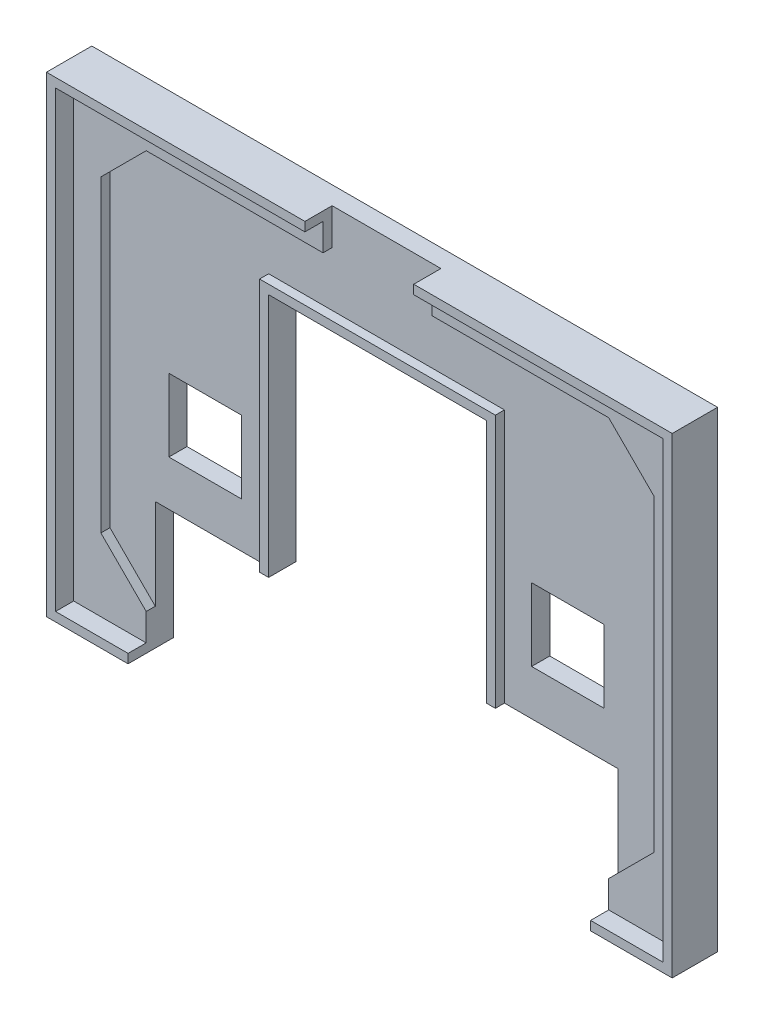
from build123d import *

# Parameters (mm, degrees)
SKICA1_W                    = 67
SKICA1_H                    = 50
P_IDAT_VYSUNUT_M1_DEPTH     = 3
ODEBRAT_VYSUNUT_M1_DEPTH    = 1
SKICA3_W                    = 8
SKICA3_H                    = 8
ODEBRAT_VYSUNUT_M2_DEPTH    = 4
VYSUNOUT_TENKOST_NN_1_DEPTH = 1
VYSUNOUT_TENKOST_NN_2_DEPTH = 5
SKICA6_W                    = 12
SKICA6_H                    = 4
ODEBRAT_VYSUNUT_M3_DEPTH    = 4
SKICA8_W                    = 4.905811643
SKICA8_H                    = 3.97370743
SKICA8_W_2                  = 4.905811642
ODEBRAT_VYSUNUT_M4_DEPTH    = 1
SKICA9_W                    = 2.796312636
SKICA9_H                    = 1.35
P_IDAT_VYSUNUT_M2_DEPTH     = 1
ODEBRAT_VYSUNUT_M5_DEPTH    = 1


with BuildPart() as part:
    # Skica1 → Přidat vysunutím1 (new body)
    with BuildSketch(Plane.XY):
        Rectangle(SKICA1_W, SKICA1_H)
    extrude(amount=P_IDAT_VYSUNUT_M1_DEPTH)

    # Skica2 → Odebrat vysunutím1 (cut)
    with BuildSketch(Plane.XY.offset(3)):
        Polygon((-25.5, -22), (-30.5, -17), (-30.5, 17), (-25.5, 22), (25.5, 22), (30.5, 17), (30.5, -17), (25.5, -22), align=None)
    extrude(amount=-ODEBRAT_VYSUNUT_M1_DEPTH, mode=Mode.SUBTRACT)

    # Skica3 → Odebrat vysunutím2 (cut, through all)
    with BuildSketch(Plane(origin=(0, 0, 0), x_dir=(-1, 0, 0), z_dir=(0, 0, -1))):
        with Locations((20, -3)):
            Rectangle(SKICA3_W, SKICA3_H)
        with Locations((-20, -3)):
            Rectangle(SKICA3_W, SKICA3_H)
        Polygon((25.5, -25), (-25.5, -25), (-25.5, -12), (-12, -12), (-12, 15), (12, 15), (12, -12), (25.5, -12), align=None)
    extrude(amount=-ODEBRAT_VYSUNUT_M2_DEPTH, mode=Mode.SUBTRACT)

    # Skica4 → Vysunout tenkostěnný1 (add)
    with BuildSketch(Plane.XY.offset(2)):
        Polygon((-12, -12), (-12, 15), (12, 15), (12, -12), (13, -12), (13, 16), (-13, 16), (-13, -12), align=None)
    extrude(amount=VYSUNOUT_TENKOST_NN_1_DEPTH)

    # Skica5 → Vysunout tenkostěnný2 (add)
    with BuildSketch(Plane(origin=(0, 0, 0), x_dir=(-1, 0, 0), z_dir=(0, 0, -1))):
        Polygon((-25.5, -25), (-33.5, -25), (-33.5, 25), (33.5, 25), (33.5, -25), (25.5, -25), (25.5, -26), (34.5, -26), (34.5, 26), (-34.5, 26), (-34.5, -26), (-25.5, -26), align=None)
    extrude(amount=-VYSUNOUT_TENKOST_NN_2_DEPTH)

    # Skica6 → Odebrat vysunutím3 (cut, through all)
    with BuildSketch(Plane.XY.offset(2)):
        with Locations((0, 24)):
            Rectangle(SKICA6_W, SKICA6_H)
    extrude(amount=ODEBRAT_VYSUNUT_M3_DEPTH, mode=Mode.SUBTRACT)

    # Skica8 → Odebrat vysunutím4 (cut)
    with BuildSketch(Plane(origin=(0, 0, 0), x_dir=(-1, 0, 0), z_dir=(0, 0, -1))):
        Polygon((-29.360201617, 11.223446344), (-29.360201617, 12.670660778), (-28.060161531, 12.670660778), (-28.060161531, 14.01975898), (-25.06761643, 14.01975898), (-25.06761643, 17.674588653), (-26.463929066, 17.674588653), (-26.463929066, 18.925570622), (-30.65839802, 18.925570622), (-30.65839802, 17.674588653), (-32.05839802, 17.674588653), (-32.05839802, 9.8988772), (-30.68477076, 9.8988772), (-30.68477076, 11.223446344), align=None)
        with Locations((-30.513067353, 22.114348189)):
            Rectangle(SKICA8_W, SKICA8_H)
        Polygon((-21.557554904, 13.547062013), (-23.312585667, 13.547062013), (-23.312585667, 9.373239167), (-21.108219536, 9.373239167), (-21.108219536, 9.8988772), (-20.306572936, 9.8988772), (-20.306572936, 10.925874395), (-21.325302348, 10.925874395), (-21.325302348, 10.184346441), (-22.071409423, 10.184346441), (-22.071409423, 11.947053561), (-21.557554904, 11.947053561), align=None)
        Polygon((-23.312585667, 13.547062013), (-25.06761643, 13.547062013), (-25.06761643, 11.947053561), (-24.553761911, 11.947053561), (-24.553761911, 10.184346441), (-25.299868987, 10.184346441), (-25.299868987, 10.925874395), (-26.318598399, 10.925874395), (-26.318598399, 9.8988772), (-25.516951799, 9.8988772), (-25.516951799, 9.373239167), (-23.312585667, 9.373239167), align=None)
        Polygon((-20.161242268, 18.925570622), (-15.966773314, 18.925570622), (-15.966773314, 17.674588653), (-14.566773314, 17.674588653), (-14.566773314, 9.8988772), (-15.940400574, 9.8988772), (-15.940400574, 11.223446344), (-17.264969718, 11.223446344), (-17.264969718, 12.670660778), (-18.565009803, 12.670660778), (-18.565009803, 14.01975898), (-21.557554904, 14.01975898), (-21.557554904, 17.674588653), (-20.161242268, 17.674588653), align=None)
        with Locations((-16.112103982, 22.114348189)):
            Rectangle(SKICA8_W_2, SKICA8_H)
        with Locations((16.112103982, 22.114348189)):
            Rectangle(SKICA8_W_2, SKICA8_H)
        Polygon((17.264969718, 11.223446344), (17.264969718, 12.670660778), (18.565009803, 12.670660778), (18.565009803, 14.01975898), (21.557554904, 14.01975898), (21.557554904, 17.674588653), (20.161242268, 17.674588653), (20.161242268, 18.925570622), (15.966773314, 18.925570622), (15.966773314, 17.674588653), (14.566773314, 17.674588653), (14.566773314, 9.8988772), (15.940400574, 9.8988772), (15.940400574, 11.223446344), align=None)
        Polygon((26.463929066, 18.925570622), (30.65839802, 18.925570622), (30.65839802, 17.674588653), (32.05839802, 17.674588653), (32.05839802, 9.8988772), (30.68477076, 9.8988772), (30.68477076, 11.223446344), (29.360201617, 11.223446344), (29.360201617, 12.670660778), (28.060161531, 12.670660778), (28.060161531, 14.01975898), (25.06761643, 14.01975898), (25.06761643, 17.674588653), (26.463929066, 17.674588653), align=None)
        with Locations((30.513067353, 22.114348189)):
            Rectangle(SKICA8_W, SKICA8_H)
        Polygon((23.312585667, 13.547062013), (23.312585667, 9.373239167), (25.516951799, 9.373239167), (25.516951799, 9.8988772), (26.318598399, 9.8988772), (26.318598399, 10.925874395), (25.299868987, 10.925874395), (25.299868987, 10.184346441), (24.553761911, 10.184346441), (24.553761911, 11.947053561), (25.06761643, 11.947053561), (25.06761643, 13.547062013), align=None)
        Polygon((21.108219536, 9.8988772), (21.108219536, 9.373239167), (23.312585667, 9.373239167), (23.312585667, 13.547062013), (21.557554904, 13.547062013), (21.557554904, 11.947053561), (22.071409423, 11.947053561), (22.071409423, 10.184346441), (21.325302348, 10.184346441), (21.325302348, 10.925874395), (20.306572936, 10.925874395), (20.306572936, 9.8988772), align=None)
    extrude(amount=-ODEBRAT_VYSUNUT_M4_DEPTH, mode=Mode.SUBTRACT)

    # Skica9 → Přidat vysunutím2 (add)
    with BuildSketch(Plane(origin=(0, 0, 1), x_dir=(-1, 0, 0), z_dir=(0, 0, -1))):
        with Locations((-27.962045299, 14.69475898)):
            Rectangle(SKICA9_W, SKICA9_H)
        with Locations((18.663126036, 14.69475898)):
            Rectangle(SKICA9_W, SKICA9_H)
        with Locations((-18.663126036, 14.69475898)):
            Rectangle(SKICA9_W, SKICA9_H)
        with Locations((27.962045299, 14.69475898)):
            Rectangle(SKICA9_W, SKICA9_H)
    extrude(amount=P_IDAT_VYSUNUT_M2_DEPTH)

    # Skica10 → Odebrat vysunutím5 (cut)
    with BuildSketch(Plane(origin=(0, 0, 0), x_dir=(-1, 0, 0), z_dir=(0, 0, -1))):
        with BuildLine():
            add(Edge.make_bspline(
                [(-10.786907005, 22.633495771), (-10.786266554, 22.662273757), (-10.785065291, 22.716251294), (-10.781015242, 22.792150536), (-10.777826972, 22.858131192), (-10.773419164, 22.914175061), (-10.767018799, 22.960033947), (-10.761783362, 22.995924657), (-10.755050028, 23.021801733), (-10.743304689, 23.046301046), (-10.707137617, 23.064261365), (-10.648706566, 23.075694736), (-10.562846735, 23.084823101), (-10.470072011, 23.088864717), (-10.366127946, 23.092135969), (-10.248626659, 23.092610824), (-10.095176257, 23.09404485), (-9.9057582, 23.095140352), (-9.679976139, 23.096282608), (-9.418230216, 23.097825825), (-9.120116074, 23.097333936), (-8.90951957, 23.097408397), (-8.798027303, 23.097447818)],
                knots=[0, 0, 0, 0, 8.635e-05, 0.000161963, 0.000227997, 0.000284546, 0.000330495, 0.000366956, 0.000393139, 0.00041084, 0.000446424, 0.000506903, 0.000591368, 0.000704219, 0.000785775, 0.000903268, 0.001056724, 0.001246145, 0.001471531, 0.00173408, 0.002031393, 0.00236587, 0.00236587, 0.00236587, 0.00236587], degree=3))
            add(Edge.make_bspline(
                [(-8.798027303, 23.097447818), (-8.721300794, 23.097623006), (-8.572642073, 23.097962435), (-8.356857287, 23.095591203), (-8.155436229, 23.097224082), (-7.968836638, 23.093300977), (-7.796584603, 23.093172861), (-7.638744665, 23.090308063), (-7.494886817, 23.087872512), (-7.365385569, 23.08601749), (-7.250322392, 23.081901362), (-7.149567349, 23.078952324), (-7.063288556, 23.073811114), (-6.991306922, 23.069268529), (-6.933835115, 23.064367368), (-6.890316944, 23.060349086), (-6.861651659, 23.054787307), (-6.83989128, 23.047755157), (-6.827627065, 23.028047679), (-6.816100638, 23.001964189), (-6.805409555, 22.966852234), (-6.797149634, 22.922717171), (-6.791991561, 22.86933108), (-6.786774702, 22.807019906), (-6.784944001, 22.73580466), (-6.784309323, 22.685444484), (-6.783971908, 22.658671464)],
                knots=[0, 0, 0, 0, 0.000230178, 0.000445973, 0.000647378, 0.000834413, 0.001005852, 0.001164117, 0.001307998, 0.001437495, 0.00155264, 0.001653407, 0.001739857, 0.001811947, 0.001869691, 0.001913115, 0.001942505, 0.00195809, 0.001979435, 0.002008406, 0.002044808, 0.002088775, 0.002143055, 0.002205579, 0.002276351, 0.002356683, 0.002356683, 0.002356683, 0.002356683], degree=3))
            Line((-6.783971908, 22.658671464), (-6.783971908, 22.31100714))
            Line((-6.783971908, 22.31100714), (-6.519027716, 22.31100714))
            Line((-6.519027716, 22.31100714), (-6.402739994, 22.31100714))
            add(Edge.make_bspline(
                [(-6.402739994, 22.31100714), (-6.376684614, 22.310020117), (-6.328998931, 22.308213701), (-6.264901459, 22.291852058), (-6.217525297, 22.260107453), (-6.192127032, 22.222101776), (-6.182431537, 22.182930855), (-6.173354125, 22.14317585), (-6.168504966, 22.092069951), (-6.163927997, 22.030508761), (-6.158409105, 21.958626782), (-6.157195089, 21.875419522), (-6.153807933, 21.781540283), (-6.154314269, 21.715186475), (-6.154579597, 21.680415986)],
                knots=[0, 0, 0, 0, 7.8155e-05, 0.000143037, 0.000195581, 0.000245789, 0.00027576, 0.000316203, 0.0003681, 0.000429429, 0.000501519, 0.000584274, 0.000679013, 0.000783312, 0.000783312, 0.000783312, 0.000783312], degree=3))
            Line((-6.154579597, 21.680415986), (-6.154579597, 21.383103047))
            add(Edge.make_bspline(
                [(-6.154579597, 21.383103047), (-6.155058222, 21.319965229), (-6.155957917, 21.20128179), (-6.15604519, 21.034613396), (-6.160588411, 20.891170494), (-6.16316869, 20.77084373), (-6.168956341, 20.673599539), (-6.176496263, 20.599440439), (-6.182124106, 20.547278766), (-6.191852254, 20.521857931), (-6.195340242, 20.512743394)],
                knots=[0, 0, 0, 0, 0.000189421, 0.000356064, 0.00049997, 0.000619909, 0.0007172, 0.000791875, 0.000844104, 0.000873298, 0.000873298, 0.000873298, 0.000873298], degree=3))
            add(Edge.make_bspline(
                [(-6.195340242, 20.512743394), (-6.2069217, 20.503571286), (-6.23601227, 20.480532576), (-6.304213399, 20.465201193), (-6.397481857, 20.455352631), (-6.469777853, 20.454488484), (-6.510635819, 20.454000112)],
                knots=[0, 0, 0, 0, 4.3901e-05, 0.000110272, 0.000204402, 0.000326737, 0.000326737, 0.000326737, 0.000326737], degree=3))
            Line((-6.510635819, 20.454000112), (-6.783971908, 20.454000112))
            Line((-6.783971908, 20.454000112), (-6.783971908, 20.114727685))
            add(Edge.make_bspline(
                [(-6.783971908, 20.114727685), (-6.784257461, 20.087151703), (-6.784791433, 20.035585806), (-6.787247214, 19.962446481), (-6.790601158, 19.898859863), (-6.795259872, 19.844042527), (-6.801314369, 19.798862688), (-6.812252733, 19.763267815), (-6.819896912, 19.735808941), (-6.835244345, 19.711605643), (-6.876691653, 19.701097412), (-6.942376853, 19.693837875), (-7.045320495, 19.683430325), (-7.183501547, 19.678040096), (-7.357772143, 19.669771831), (-7.568410481, 19.666411346), (-7.814552884, 19.660581657), (-7.990802718, 19.659659109), (-8.084716017, 19.659167537)],
                knots=[0, 0, 0, 0, 8.2729e-05, 0.000154699, 0.000219537, 0.000273697, 0.000319818, 0.000355883, 0.000385076, 0.000405702, 0.000437982, 0.000505799, 0.000608151, 0.000746205, 0.000921384, 0.001131236, 0.001378244, 0.001659982, 0.001659982, 0.001659982, 0.001659982], degree=3))
            Line((-8.084716017, 19.659167537), (-9.302739994, 19.650775639))
            Line((-9.302739994, 19.650775639), (-9.302739994, 18.53225559))
            add(Edge.make_bspline(
                [(-9.302739994, 18.53225559), (-9.303427373, 18.444740909), (-9.304717434, 18.280494864), (-9.308175997, 18.050683803), (-9.312999066, 17.853735098), (-9.318237049, 17.689655129), (-9.326409208, 17.559522224), (-9.330997438, 17.460560055), (-9.342150664, 17.398393473), (-9.347620268, 17.354831871), (-9.377806854, 17.337867599), (-9.417057985, 17.327941067), (-9.47601302, 17.318790607), (-9.553104164, 17.310618034), (-9.649972093, 17.30531378), (-9.765441105, 17.30023359), (-9.900559718, 17.298409424), (-9.996870749, 17.297783067), (-10.048420027, 17.297447818)],
                knots=[0, 0, 0, 0, 0.000262557, 0.000492763, 0.000689432, 0.000853783, 0.000984654, 0.001082027, 0.001147471, 0.001180083, 0.00120336, 0.001244698, 0.001303037, 0.001381412, 0.001477506, 0.001593893, 0.001728185, 0.00188284, 0.00188284, 0.00188284, 0.00188284], degree=3))
            add(Edge.make_bspline(
                [(-10.048420027, 17.297447818), (-10.08598352, 17.297487035), (-10.156714777, 17.29756088), (-10.257023598, 17.297074039), (-10.345334758, 17.298616002), (-10.422458822, 17.299772489), (-10.487603133, 17.300839712), (-10.541135832, 17.3022989), (-10.582764272, 17.302779621), (-10.62115527, 17.306139392), (-10.658083057, 17.310210987), (-10.694479459, 17.321147791), (-10.723630137, 17.335083955), (-10.744318498, 17.351504239), (-10.755127017, 17.372986414), (-10.761749218, 17.39901863), (-10.767032188, 17.434843116), (-10.773413821, 17.480727406), (-10.777830936, 17.53676205), (-10.781004014, 17.602746098), (-10.785114305, 17.678643064), (-10.786482752, 17.750209882), (-10.788581336, 17.818135039), (-10.787682518, 17.8836888), (-10.789501758, 17.962403189), (-10.790910773, 18.054711825), (-10.790021921, 18.160219317), (-10.792217834, 18.279295156), (-10.791628255, 18.411572608), (-10.791365117, 18.557433989), (-10.793342184, 18.716074949), (-10.792857994, 18.88831204), (-10.79253785, 19.073735053), (-10.794561554, 19.272738054), (-10.793964515, 19.484936166), (-10.79414007, 19.710717645), (-10.794087699, 19.949687067), (-10.794106392, 20.197447818), (-10.794087699, 20.445208568), (-10.79414007, 20.68417799), (-10.793964515, 20.90995947), (-10.794561554, 21.122157582), (-10.792537849, 21.321160583), (-10.792857995, 21.506583596), (-10.793342181, 21.678820687), (-10.791365127, 21.837461647), (-10.791628222, 21.983323027), (-10.792217943, 22.115600482), (-10.790021577, 22.234676311), (-10.790911842, 22.340183833), (-10.789498512, 22.432492377), (-10.787691993, 22.511207038), (-10.788555095, 22.576760038), (-10.787417731, 22.615913959), (-10.786907005, 22.633495771)],
                knots=[0, 0, 0, 0, 0.000112691, 0.000212195, 0.000300918, 0.000377653, 0.0004436, 0.000496363, 0.000538339, 0.000568406, 0.000611979, 0.000649528, 0.000681696, 0.000708876, 0.000726576, 0.000752759, 0.000789221, 0.000835169, 0.000891719, 0.000957753, 0.001033366, 0.001119716, 0.001172478, 0.001237216, 0.001316349, 0.001408667, 0.001514165, 0.001632857, 0.001765928, 0.001910988, 0.002070439, 0.002241873, 0.002427694, 0.002626705, 0.002838901, 0.003064283, 0.003304051, 0.003555808, 0.003807565, 0.004047334, 0.004272716, 0.004484911, 0.004683923, 0.004869743, 0.005041178, 0.005200628, 0.005345688, 0.00547876, 0.005597451, 0.005702949, 0.005795268, 0.005874401, 0.005939138, 0.005991901, 0.005991901, 0.005991901, 0.005991901], degree=3))
        make_face()
        with BuildLine():
            add(Edge.make_bspline(
                [(-7.645939663, 20.744119996), (-7.645939663, 20.745718453), (-7.645939663, 20.752511894), (-7.645939663, 20.767297618), (-7.645939663, 20.79247331), (-7.645939663, 20.827239743), (-7.645939663, 20.872396144), (-7.645939663, 20.927143284), (-7.645939663, 20.991880779), (-7.645939663, 21.066608628), (-7.645939663, 21.151326831), (-7.645939663, 21.246035388), (-7.645939663, 21.3507343), (-7.645939663, 21.465423565), (-7.645939663, 21.590103185), (-7.645939663, 21.724773159), (-7.645939663, 21.869433487), (-7.645939663, 21.969337028), (-7.645939663, 22.020887256)],
                knots=[0, 0, 0, 0, 4.795e-06, 2.038e-05, 4.4357e-05, 8.0322e-05, 0.00012468, 0.000179826, 0.000244564, 0.000318892, 0.00040401, 0.000498718, 0.000603018, 0.000718107, 0.000842786, 0.000977057, 0.001122117, 0.001276767, 0.001276767, 0.001276767, 0.001276767], degree=3))
            Line((-7.645939663, 22.020887256), (-8.465947931, 22.029279153))
            add(Edge.make_bspline(
                [(-8.465947931, 22.029279153), (-8.467946002, 22.029279153), (-8.475538671, 22.029279153), (-8.49272208, 22.029279153), (-8.521094686, 22.029279153), (-8.561056102, 22.029279153), (-8.612206716, 22.029279153), (-8.67494614, 22.029279153), (-8.74887476, 22.029279153), (-8.802023444, 22.029279153), (-8.83039605, 22.029279153)],
                knots=[0, 0, 0, 0, 5.994e-06, 2.2778e-05, 5.155e-05, 9.1112e-05, 0.000142662, 0.000205002, 0.00027933, 0.000364448, 0.000364448, 0.000364448, 0.000364448], degree=3))
            add(Edge.make_bspline(
                [(-8.83039605, 22.029279153), (-8.866766038, 22.029547199), (-8.934720089, 22.030048018), (-9.029389514, 22.026832372), (-9.109805544, 22.025100351), (-9.175619666, 22.021369249), (-9.228072176, 22.017516708), (-9.264761269, 22.010439712), (-9.291084514, 22.007662706), (-9.299711199, 21.998817189), (-9.302739994, 21.995711563)],
                knots=[0, 0, 0, 0, 0.000109095, 0.000203834, 0.000284192, 0.000350226, 0.000401999, 0.000440827, 0.000464381, 0.000477125, 0.000477125, 0.000477125, 0.000477125], degree=3))
            add(Edge.make_bspline(
                [(-9.302739994, 21.995711563), (-9.302739994, 21.991715421), (-9.302739994, 21.975331241), (-9.302739994, 21.95894706), (-9.302739994, 21.946559021)],
                knots=[0, 0, 0, 0, 1.1988e-05, 4.9153e-05, 4.9153e-05, 4.9153e-05, 4.9153e-05], degree=3))
            add(Edge.make_bspline(
                [(-9.302739994, 21.946559021), (-9.302991214, 21.926972671), (-9.30356061, 21.882579764), (-9.308191959, 21.810731561), (-9.310084785, 21.73077668), (-9.310782893, 21.675620825), (-9.311131891, 21.648047239)],
                knots=[0, 0, 0, 0, 5.8756e-05, 0.000133171, 0.000215926, 0.000298654, 0.000298654, 0.000298654, 0.000298654], degree=3))
            add(Edge.make_bspline(
                [(-9.311131891, 21.648047239), (-9.310740066, 21.629265338), (-9.309756232, 21.582105947), (-9.307915382, 21.505358536), (-9.303601104, 21.4246963), (-9.303001007, 21.3723176), (-9.302739994, 21.349535457)],
                knots=[0, 0, 0, 0, 5.6358e-05, 0.00014151, 0.000230297, 0.000298642, 0.000298642, 0.000298642, 0.000298642], degree=3))
            Line((-9.302739994, 21.349535457), (-9.302739994, 20.744119996))
            Line((-9.302739994, 20.744119996), (-7.645939663, 20.744119996))
        make_face(mode=Mode.SUBTRACT)
        with BuildLine():
            add(Edge.make_bspline(
                [(-4.717167443, 22.658671464), (-4.716827908, 22.685443889), (-4.716189241, 22.735802946), (-4.714384721, 22.807025537), (-4.709085605, 22.869313634), (-4.704173112, 22.922768623), (-4.695247109, 22.9666005), (-4.686502275, 23.002139329), (-4.674672244, 23.02808247), (-4.662621781, 23.047310204), (-4.642783018, 23.054705887), (-4.617606748, 23.060294909), (-4.580114603, 23.064362722), (-4.53140626, 23.069188024), (-4.470630541, 23.073878804), (-4.398331738, 23.078893445), (-4.313957265, 23.081915812), (-4.218078825, 23.086012518), (-4.110152103, 23.087874222), (-3.990271554, 23.090306706), (-3.858408249, 23.093183948), (-3.714924401, 23.093281483), (-3.559499168, 23.097236645), (-3.392441604, 23.095568452), (-3.21342277, 23.098038679), (-3.026799523, 23.097142799), (-2.840176275, 23.098038678), (-2.661157441, 23.095568457), (-2.494099878, 23.097236631), (-2.338674641, 23.09328153), (-2.195190806, 23.093183792), (-2.063327459, 23.090307214), (-1.943447046, 23.087872584), (-1.835519889, 23.08601772), (-1.739642811, 23.081899607), (-1.655662706, 23.078956968), (-1.58337568, 23.073765469), (-1.522591139, 23.069224246), (-1.473866892, 23.064482268), (-1.436811033, 23.060181017), (-1.412011102, 23.054710186), (-1.3921843, 23.047306799), (-1.380070442, 23.028099178), (-1.368566619, 23.001944348), (-1.357866994, 22.966859353), (-1.349610147, 22.922714586), (-1.344450977, 22.869331957), (-1.339234486, 22.807019623), (-1.337403668, 22.735804746), (-1.336769007, 22.685444514), (-1.336431602, 22.658671464)],
                knots=[0, 0, 0, 0, 8.0331e-05, 0.000151104, 0.000213628, 0.000267908, 0.000311874, 0.000347939, 0.000376911, 0.000398255, 0.000412741, 0.000438621, 0.000476093, 0.000525479, 0.000585612, 0.000658899, 0.000742895, 0.00083887, 0.000946792, 0.0010667, 0.001198595, 0.001342461, 0.00149713, 0.001664968, 0.0018436, 0.002034216, 0.002224831, 0.002403463, 0.002571301, 0.00272597, 0.002869836, 0.003001731, 0.003121639, 0.003229562, 0.003325536, 0.003409532, 0.003481623, 0.003542951, 0.003592337, 0.003628621, 0.0036545, 0.003668986, 0.003690331, 0.003719302, 0.003755704, 0.003799671, 0.003853951, 0.003916475, 0.003987247, 0.004067578, 0.004067578, 0.004067578, 0.004067578], degree=3))
            Line((-1.336431602, 22.658671464), (-1.336431602, 22.31100714))
            Line((-1.336431602, 22.31100714), (-1.07148741, 22.31100714))
            add(Edge.make_bspline(
                [(-1.07148741, 22.31100714), (-1.032588592, 22.310863789), (-0.962909488, 22.310607005), (-0.871901657, 22.296740203), (-0.801121071, 22.280595688), (-0.769650093, 22.254872312), (-0.756191833, 22.24387196)],
                knots=[0, 0, 0, 0, 0.000116343, 0.000208405, 0.000277419, 0.000328983, 0.000328983, 0.000328983, 0.000328983], degree=3))
            add(Edge.make_bspline(
                [(-0.756191833, 22.24387196), (-0.75094349, 22.231614308), (-0.736091374, 22.196926772), (-0.728354317, 22.123214277), (-0.719923924, 22.017149601), (-0.716158454, 21.919401896), (-0.714167555, 21.838667832), (-0.712580792, 21.782325483), (-0.713448724, 21.71477648), (-0.711662665, 21.635661342), (-0.71022035, 21.544951837), (-0.711146892, 21.443040279), (-0.708821073, 21.329959703), (-0.709988439, 21.20527041), (-0.707731247, 21.069010357), (-0.708300383, 20.9211487), (-0.708596949, 20.762100009), (-0.706577682, 20.591470404), (-0.707174671, 20.409642467), (-0.70699945, 20.216229821), (-0.707051618, 20.011627193), (-0.707032993, 19.799432109), (-0.707051525, 19.587237024), (-0.706999795, 19.382634398), (-0.707173129, 19.189621356), (-0.706583773, 19.00779347), (-0.708591049, 18.837563397), (-0.708300025, 18.678514744), (-0.707731508, 18.531052707), (-0.709986574, 18.394792633), (-0.708823632, 18.269703805), (-0.711148082, 18.156223523), (-0.710213558, 18.054311906), (-0.711688671, 17.96360267), (-0.713445252, 17.884487779), (-0.712580822, 17.816537189), (-0.714172494, 17.760200845), (-0.716129588, 17.67943773), (-0.720247599, 17.582399287), (-0.727502752, 17.47577936), (-0.73801173, 17.403986574), (-0.751732717, 17.356762453), (-0.778459518, 17.335370259), (-0.806893968, 17.320838763), (-0.843472559, 17.310136557), (-0.880787371, 17.30620276), (-0.919176322, 17.302809232), (-0.960801562, 17.302259511), (-1.013936866, 17.30088109), (-1.079079645, 17.299749838), (-1.155804718, 17.298621591), (-1.244115713, 17.297072251), (-1.344424586, 17.297561421), (-1.415155836, 17.297487222), (-1.452719324, 17.297447818)],
                knots=[0, 0, 0, 0, 3.9851e-05, 0.000112774, 0.000219801, 0.000360193, 0.000405765, 0.000462123, 0.000529259, 0.000608391, 0.000699511, 0.000801413, 0.00091411, 0.00103879, 0.001175463, 0.001322921, 0.001482367, 0.001652607, 0.001834831, 0.002027844, 0.002232847, 0.002448638, 0.00266443, 0.002869432, 0.003062446, 0.003243471, 0.003414909, 0.003573157, 0.003720614, 0.003857288, 0.003981967, 0.004095864, 0.004197765, 0.004287686, 0.004368018, 0.004435153, 0.004491511, 0.004537083, 0.004677476, 0.004783307, 0.00485623, 0.004897638, 0.004924817, 0.004955918, 0.004993467, 0.005038227, 0.005068294, 0.005109072, 0.005163033, 0.005227782, 0.005304517, 0.00539324, 0.005492744, 0.005605435, 0.005605435, 0.005605435, 0.005605435], degree=3))
            add(Edge.make_bspline(
                [(-1.452719324, 17.297447818), (-1.504268141, 17.297784412), (-1.600578311, 17.298413281), (-1.735702487, 17.300221219), (-1.85115463, 17.30535061), (-1.948070528, 17.310514962), (-2.02542279, 17.319109874), (-2.08471345, 17.327344108), (-2.123741957, 17.338586418), (-2.154741785, 17.354266449), (-2.160344708, 17.398440268), (-2.169143868, 17.460699894), (-2.177157269, 17.559391699), (-2.18197146, 17.689728546), (-2.188471505, 17.853716158), (-2.192850789, 18.050690239), (-2.196456806, 18.280492869), (-2.197724106, 18.444740216), (-2.198399357, 18.53225559)],
                knots=[0, 0, 0, 0, 0.000154655, 0.000288947, 0.000405334, 0.000501428, 0.000579804, 0.000639325, 0.000679517, 0.000703792, 0.000736404, 0.000801683, 0.000899151, 0.001029962, 0.001194313, 0.001390982, 0.001621188, 0.001883745, 0.001883745, 0.001883745, 0.001883745], degree=3))
            Line((-2.198399357, 18.53225559), (-2.198399357, 19.650775639))
            Line((-2.198399357, 19.650775639), (-3.855199688, 19.650775639))
            Line((-3.855199688, 19.650775639), (-3.855199688, 18.53225559))
            add(Edge.make_bspline(
                [(-3.855199688, 18.53225559), (-3.855887067, 18.444740909), (-3.857177128, 18.280494864), (-3.860635691, 18.050683803), (-3.86545876, 17.853735098), (-3.870696743, 17.689655129), (-3.878868902, 17.559522224), (-3.883457132, 17.460560055), (-3.894610358, 17.398393473), (-3.900079962, 17.354831871), (-3.930266548, 17.337867599), (-3.969517679, 17.327941067), (-4.028472714, 17.318790607), (-4.105563858, 17.310618034), (-4.202431787, 17.30531378), (-4.3179008, 17.30023359), (-4.453019412, 17.298409424), (-4.549330443, 17.297783067), (-4.600879721, 17.297447818)],
                knots=[0, 0, 0, 0, 0.000262557, 0.000492763, 0.000689432, 0.000853783, 0.000984654, 0.001082027, 0.001147471, 0.001180083, 0.00120336, 0.001244698, 0.001303037, 0.001381412, 0.001477506, 0.001593893, 0.001728185, 0.00188284, 0.00188284, 0.00188284, 0.00188284], degree=3))
            add(Edge.make_bspline(
                [(-4.600879721, 17.297447818), (-4.638443214, 17.297487035), (-4.709174472, 17.297560879), (-4.809483291, 17.297074042), (-4.897794456, 17.298615994), (-4.974918506, 17.299772512), (-5.040062855, 17.300839644), (-5.093595452, 17.302299082), (-5.135224159, 17.302779151), (-5.173614373, 17.306140833), (-5.21054593, 17.310203235), (-5.246929796, 17.321170605), (-5.276117436, 17.335016646), (-5.303039326, 17.356811343), (-5.316802728, 17.40395836), (-5.327273109, 17.475793304), (-5.33464672, 17.582392352), (-5.338336743, 17.679441683), (-5.341014289, 17.760192463), (-5.340147067, 17.816553785), (-5.341980035, 17.884478027), (-5.343361079, 17.963599065), (-5.342488061, 18.054322278), (-5.344675015, 18.156213236), (-5.344088059, 18.269709661), (-5.343823593, 18.39479148), (-5.34580378, 18.531053055), (-5.345318035, 18.678514641), (-5.345002273, 18.837563428), (-5.347016952, 19.007793461), (-5.346425422, 19.189621358), (-5.346599396, 19.382634398), (-5.346547475, 19.587237024), (-5.346566075, 19.799432109), (-5.346547381, 20.011627193), (-5.346599742, 20.216229822), (-5.346423875, 20.409642465), (-5.347023065, 20.591470413), (-5.344996352, 20.762099977), (-5.345318007, 20.921148806), (-5.345803505, 21.069010004), (-5.343823551, 21.205271578), (-5.34408757, 21.329953788), (-5.344669172, 21.443050548), (-5.342478004, 21.544941535), (-5.343373136, 21.635664757), (-5.34196651, 21.71478621), (-5.340145358, 21.782308662), (-5.341021101, 21.83867682), (-5.338298555, 21.919394607), (-5.335078889, 22.017195502), (-5.326171253, 22.123109396), (-5.319208318, 22.197286993), (-5.303130019, 22.23164337), (-5.297407212, 22.24387196)],
                knots=[0, 0, 0, 0, 0.000112691, 0.000212195, 0.000300918, 0.000377653, 0.0004436, 0.000496363, 0.000538339, 0.000568406, 0.000611979, 0.000649528, 0.000681696, 0.000708876, 0.000750283, 0.000823206, 0.000929038, 0.00106943, 0.001115002, 0.001171348, 0.001238493, 0.001318825, 0.001408738, 0.001510647, 0.001624537, 0.001749216, 0.00188589, 0.002033347, 0.002191594, 0.002363033, 0.002544058, 0.002737072, 0.002942074, 0.003157866, 0.003373657, 0.003578659, 0.003771673, 0.003953897, 0.004124137, 0.004283583, 0.004431041, 0.004567714, 0.004692394, 0.004805085, 0.004906993, 0.004998105, 0.005077238, 0.005144384, 0.00520073, 0.005246301, 0.005386694, 0.005493721, 0.005566643, 0.005606943, 0.005606943, 0.005606943, 0.005606943], degree=3))
            add(Edge.make_bspline(
                [(-5.297407212, 22.24387196), (-5.284366233, 22.254898607), (-5.253240671, 22.281216463), (-5.181943406, 22.296386897), (-5.090736804, 22.310714573), (-5.02102738, 22.310902326), (-4.982111635, 22.31100714)],
                knots=[0, 0, 0, 0, 5.0593e-05, 0.000120754, 0.000212815, 0.000329159, 0.000329159, 0.000329159, 0.000329159], degree=3))
            Line((-4.982111635, 22.31100714), (-4.717167443, 22.31100714))
            Line((-4.717167443, 22.31100714), (-4.717167443, 22.658671464))
        make_face()
        with BuildLine():
            add(Edge.make_bspline(
                [(-2.198399357, 20.744119996), (-2.198399357, 20.745718453), (-2.198399357, 20.752511894), (-2.198399357, 20.767297618), (-2.198399357, 20.79247331), (-2.198399357, 20.827239743), (-2.198399357, 20.872396144), (-2.198399357, 20.927143284), (-2.198399357, 20.991880779), (-2.198399357, 21.066608628), (-2.198399357, 21.151326831), (-2.198399357, 21.246035388), (-2.198399357, 21.3507343), (-2.198399357, 21.465423565), (-2.198399357, 21.590103185), (-2.198399357, 21.724773159), (-2.198399357, 21.869433487), (-2.198399357, 21.969337028), (-2.198399357, 22.020887256)],
                knots=[0, 0, 0, 0, 4.795e-06, 2.038e-05, 4.4357e-05, 8.0322e-05, 0.00012468, 0.000179826, 0.000244564, 0.000318892, 0.00040401, 0.000498718, 0.000603018, 0.000718107, 0.000842786, 0.000977057, 0.001122117, 0.001276767, 0.001276767, 0.001276767, 0.001276767], degree=3))
            Line((-2.198399357, 22.020887256), (-3.018407625, 22.029279153))
            add(Edge.make_bspline(
                [(-3.018407625, 22.029279153), (-3.020405696, 22.029279153), (-3.027998365, 22.029279153), (-3.045181774, 22.029279153), (-3.07355438, 22.029279153), (-3.113515797, 22.029279153), (-3.16466641, 22.029279153), (-3.227405834, 22.029279153), (-3.301334454, 22.029279153), (-3.354483138, 22.029279153), (-3.382855744, 22.029279153)],
                knots=[0, 0, 0, 0, 5.994e-06, 2.2778e-05, 5.155e-05, 9.1112e-05, 0.000142662, 0.000205002, 0.00027933, 0.000364448, 0.000364448, 0.000364448, 0.000364448], degree=3))
            add(Edge.make_bspline(
                [(-3.382855744, 22.029279153), (-3.419225732, 22.029547199), (-3.487179783, 22.030048018), (-3.581849208, 22.026832372), (-3.662265238, 22.025100351), (-3.72807936, 22.021369249), (-3.78053187, 22.017516708), (-3.817220963, 22.010439712), (-3.843544208, 22.007662706), (-3.852170893, 21.998817189), (-3.855199688, 21.995711563)],
                knots=[0, 0, 0, 0, 0.000109095, 0.000203834, 0.000284192, 0.000350226, 0.000401999, 0.000440827, 0.000464381, 0.000477125, 0.000477125, 0.000477125, 0.000477125], degree=3))
            add(Edge.make_bspline(
                [(-3.855199688, 21.995711563), (-3.855199688, 21.991715421), (-3.855199688, 21.975331241), (-3.855199688, 21.95894706), (-3.855199688, 21.946559021)],
                knots=[0, 0, 0, 0, 1.1988e-05, 4.9153e-05, 4.9153e-05, 4.9153e-05, 4.9153e-05], degree=3))
            add(Edge.make_bspline(
                [(-3.855199688, 21.946559021), (-3.855450908, 21.926972671), (-3.856020304, 21.882579764), (-3.860651653, 21.810731561), (-3.862544479, 21.73077668), (-3.863242587, 21.675620825), (-3.863591585, 21.648047239)],
                knots=[0, 0, 0, 0, 5.8756e-05, 0.000133171, 0.000215926, 0.000298654, 0.000298654, 0.000298654, 0.000298654], degree=3))
            add(Edge.make_bspline(
                [(-3.863591585, 21.648047239), (-3.86319976, 21.629265338), (-3.862215926, 21.582105947), (-3.860375076, 21.505358536), (-3.856060798, 21.4246963), (-3.855460701, 21.3723176), (-3.855199688, 21.349535457)],
                knots=[0, 0, 0, 0, 5.6358e-05, 0.00014151, 0.000230297, 0.000298642, 0.000298642, 0.000298642, 0.000298642], degree=3))
            Line((-3.855199688, 21.349535457), (-3.855199688, 20.744119996))
            Line((-3.855199688, 20.744119996), (-2.198399357, 20.744119996))
        make_face(mode=Mode.SUBTRACT)
        with BuildLine():
            add(Edge.make_bspline(
                [(0.108173607, 22.633495771), (0.108813959, 22.662273881), (0.110015039, 22.716251651), (0.114066287, 22.792149377), (0.11725085, 22.858134717), (0.121669567, 22.914164804), (0.12803971, 22.96006187), (0.133353962, 22.995853008), (0.139902656, 23.021963355), (0.151038312, 23.043472566), (0.17119369, 23.061447454), (0.201787056, 23.075057505), (0.239992336, 23.084380331), (0.278314912, 23.088790785), (0.317919064, 23.092051533), (0.359936232, 23.092620709), (0.413073445, 23.09403113), (0.477816099, 23.095143472), (0.554141946, 23.09626399), (0.641653381, 23.09782536), (0.740363935, 23.097334787), (0.80989633, 23.097408725), (0.846660585, 23.097447818)],
                knots=[0, 0, 0, 0, 8.635e-05, 0.000161963, 0.000227997, 0.000284546, 0.000330495, 0.000366956, 0.000393139, 0.00041084, 0.000438827, 0.000472072, 0.000510454, 0.000556403, 0.000587665, 0.000629641, 0.000682404, 0.000747153, 0.000823888, 0.000911412, 0.001009717, 0.00112001, 0.00112001, 0.00112001, 0.00112001], degree=3))
            add(Edge.make_bspline(
                [(0.846660585, 23.097447818), (0.896613467, 23.097152531), (0.990530745, 23.096597358), (1.122413363, 23.094263891), (1.23592359, 23.09077808), (1.331096588, 23.086347104), (1.408036074, 23.080051446), (1.466348944, 23.069895184), (1.507150198, 23.062238067), (1.534006687, 23.049595491), (1.547766362, 23.028432163), (1.556151301, 23.00104755), (1.566168931, 22.96565295), (1.57295421, 22.9202113), (1.577136133, 22.865727213), (1.580753616, 22.8021687), (1.58310857, 22.729419378), (1.583655981, 22.677854828), (1.58394872, 22.650279566)],
                knots=[0, 0, 0, 0, 0.00014986, 0.000281755, 0.000395701, 0.000490531, 0.000567594, 0.000627115, 0.000667822, 0.000692508, 0.000713134, 0.000741198, 0.00077842, 0.000823357, 0.000878711, 0.000942352, 0.001014322, 0.001097051, 0.001097051, 0.001097051, 0.001097051], degree=3))
            Line((1.58394872, 22.650279566), (1.58394872, 22.31100714))
            Line((1.58394872, 22.31100714), (1.85728481, 22.31100714))
            Line((1.85728481, 22.31100714), (1.865676707, 22.31100714))
            add(Edge.make_bspline(
                [(1.865676707, 22.31100714), (1.904045596, 22.310382315), (1.97214832, 22.309273283), (2.06169001, 22.300674963), (2.125670857, 22.286513002), (2.173369503, 22.259286862), (2.193054791, 22.201729677), (2.205205164, 22.121271695), (2.212716855, 22.004096232), (2.213115344, 21.914552568), (2.213341031, 21.863838888)],
                knots=[0, 0, 0, 0, 0.000115145, 0.000204376, 0.000268936, 0.000312161, 0.000360976, 0.000442577, 0.000559167, 0.000711439, 0.000711439, 0.000711439, 0.000711439], degree=3))
            Line((2.213341031, 21.863838888), (2.213341031, 21.514975722))
            Line((2.213341031, 21.514975722), (2.486677121, 21.514975722))
            Line((2.486677121, 21.514975722), (2.503460916, 21.514975722))
            Line((2.503460916, 21.514975722), (2.537028506, 21.514975722))
            add(Edge.make_bspline(
                [(2.537028506, 21.514975722), (2.570576712, 21.514146103), (2.629821508, 21.512681028), (2.708497819, 21.506167972), (2.763971818, 21.491069553), (2.805795753, 21.466361874), (2.82242573, 21.416645369), (2.834601483, 21.348412435), (2.842043172, 21.250459003), (2.842485405, 21.175672632), (2.842733342, 21.133743808)],
                knots=[0, 0, 0, 0, 0.000100767, 0.00017795, 0.000235595, 0.000273505, 0.000316962, 0.000385381, 0.000484043, 0.000609944, 0.000609944, 0.000609944, 0.000609944], degree=3))
            Line((2.842733342, 21.133743808), (2.842733342, 21.076199368))
            Line((2.842733342, 21.076199368), (2.842733342, 20.728535044))
            add(Edge.make_bspline(
                [(2.842733342, 20.728535044), (2.871107407, 20.729284315), (2.93906189, 20.731078783), (3.046575184, 20.735279481), (3.153578369, 20.741898012), (3.221161947, 20.743469439), (3.249140949, 20.744119996)],
                knots=[0, 0, 0, 0, 8.5152e-05, 0.000203934, 0.000322771, 0.000406724, 0.000406724, 0.000406724, 0.000406724], degree=3))
            Line((3.249140949, 20.744119996), (3.249140949, 21.863838888))
            add(Edge.make_bspline(
                [(3.249140949, 21.863838888), (3.249816416, 21.951354232), (3.251084122, 22.115601523), (3.25468751, 22.345404516), (3.259074706, 22.542377504), (3.26555224, 22.706368227), (3.270426295, 22.8366968), (3.278263271, 22.935008872), (3.287274962, 22.996874226), (3.292795213, 23.040630646), (3.3237997, 23.056308621), (3.362826193, 23.067551819), (3.422117793, 23.07578564), (3.499469676, 23.084380719), (3.596385712, 23.089545009), (3.711837806, 23.094674422), (3.846961999, 23.096482353), (3.943272166, 23.097111223), (3.994820982, 23.097447818)],
                knots=[0, 0, 0, 0, 0.000262557, 0.000492763, 0.000689432, 0.000853783, 0.000984594, 0.001082062, 0.001146153, 0.001178765, 0.001203039, 0.001243232, 0.001302753, 0.001381128, 0.001477223, 0.001593609, 0.001727901, 0.001882556, 0.001882556, 0.001882556, 0.001882556], degree=3))
            add(Edge.make_bspline(
                [(3.994820982, 23.097447818), (4.032384466, 23.097408397), (4.103115709, 23.097334169), (4.20342463, 23.097823535), (4.291735473, 23.096273574), (4.368461002, 23.095147201), (4.433602454, 23.094010491), (4.486741457, 23.092647288), (4.528357332, 23.092059036), (4.566774328, 23.088780897), (4.603842464, 23.084290037), (4.640763873, 23.075471898), (4.669518037, 23.060725647), (4.689262266, 23.043507737), (4.700374138, 23.021951672), (4.70693139, 22.995858187), (4.712241992, 22.960059853), (4.718613518, 22.91416554), (4.723031823, 22.858134492), (4.726216117, 22.792149325), (4.730269333, 22.716252248), (4.731854083, 22.644687263), (4.733385841, 22.576753317), (4.734964381, 22.511221209), (4.734086938, 22.432484216), (4.735870604, 22.340180793), (4.737321096, 22.23468519), (4.736395278, 22.115591667), (4.738713963, 21.983328028), (4.737555443, 21.837460662), (4.739806551, 21.678820983), (4.739239846, 21.506583507), (4.738944502, 21.321160609), (4.740960825, 21.122157574), (4.740365964, 20.909959472), (4.740540879, 20.684177989), (4.740488698, 20.445208568), (4.740507323, 20.197447818), (4.740488698, 19.949687067), (4.740540879, 19.710717646), (4.740365964, 19.484936164), (4.740960825, 19.272738061), (4.738944502, 19.073735026), (4.739239846, 18.888312129), (4.739806551, 18.716074652), (4.737555443, 18.557434974), (4.738713963, 18.411567607), (4.736395278, 18.279303969), (4.737321096, 18.160210446), (4.735870604, 18.054714843), (4.734086938, 17.96241142), (4.734964382, 17.883674425), (4.733385836, 17.818142323), (4.7318541, 17.750208356), (4.730269225, 17.678643491), (4.726216443, 17.602746), (4.723030836, 17.536762086), (4.718616389, 17.480727357), (4.712234177, 17.434843239), (4.706951443, 17.399018316), (4.700328904, 17.372987122), (4.689521272, 17.35150214), (4.668827874, 17.335097848), (4.639356765, 17.320915388), (4.601663334, 17.310126014), (4.563547304, 17.306262911), (4.524370624, 17.302763695), (4.482341601, 17.302291744), (4.42880845, 17.300872351), (4.364064617, 17.299763957), (4.288139171, 17.298616418), (4.200627374, 17.297067645), (4.101517264, 17.297560571), (4.031585244, 17.297486669), (3.994820982, 17.297447818)],
                knots=[0, 0, 0, 0, 0.000112691, 0.000212195, 0.000300918, 0.000377653, 0.000442401, 0.000496363, 0.000537141, 0.000567208, 0.000611968, 0.00064919, 0.000680291, 0.000708278, 0.000725979, 0.000752162, 0.000788623, 0.000834572, 0.000891121, 0.000957156, 0.001032768, 0.001119118, 0.001171881, 0.00123663, 0.001315753, 0.001408072, 0.001513577, 0.001632262, 0.001765339, 0.001910399, 0.00206985, 0.002241284, 0.002427105, 0.002626116, 0.002838311, 0.003063694, 0.003303462, 0.003555219, 0.003806976, 0.004046744, 0.004272127, 0.004484322, 0.004683333, 0.004869154, 0.005040588, 0.005200039, 0.005345099, 0.005478176, 0.005596861, 0.005702366, 0.005794685, 0.005873809, 0.005938557, 0.00599132, 0.00607767, 0.006153282, 0.006219317, 0.006275866, 0.006321815, 0.006358276, 0.006384459, 0.00640216, 0.00642934, 0.006461508, 0.006500207, 0.006546155, 0.006576222, 0.006618199, 0.00667216, 0.006736908, 0.006812445, 0.006899969, 0.006999473, 0.007109766, 0.007109766, 0.007109766, 0.007109766], degree=3))
            add(Edge.make_bspline(
                [(3.994820982, 17.297447818), (3.944867805, 17.297745073), (3.850949974, 17.298303948), (3.71907096, 17.30061329), (3.605549776, 17.304172445), (3.510408102, 17.308393759), (3.43344345, 17.315256556), (3.375404202, 17.323957589), (3.333560422, 17.330610892), (3.314920651, 17.342218534), (3.307884231, 17.34660036)],
                knots=[0, 0, 0, 0, 0.00014986, 0.000281755, 0.000395701, 0.000490531, 0.000567594, 0.000626933, 0.000667641, 0.000692327, 0.000692327, 0.000692327, 0.000692327], degree=3))
            add(Edge.make_bspline(
                [(3.307884231, 17.34660036), (3.303489177, 17.354854755), (3.291756315, 17.376890357), (3.285632876, 17.424619233), (3.274274985, 17.491179648), (3.270839627, 17.580048326), (3.263467493, 17.688956945), (3.260955112, 17.818947428), (3.258309641, 17.969584828), (3.257802454, 18.077091964), (3.257532846, 18.134239881)],
                knots=[0, 0, 0, 0, 2.7884e-05, 7.4439e-05, 0.000142256, 0.000231172, 0.000340432, 0.000469957, 0.00062103, 0.000792468, 0.000792468, 0.000792468, 0.000792468], degree=3))
            Line((3.257532846, 18.134239881), (3.257532846, 18.879919914))
            Line((3.257532846, 18.879919914), (2.984196757, 18.879919914))
            Line((2.984196757, 18.879919914), (2.975804859, 18.879919914))
            Line((2.975804859, 18.879919914), (2.942237269, 18.879919914))
            add(Edge.make_bspline(
                [(2.942237269, 18.879919914), (2.907423607, 18.880338355), (2.845970993, 18.881076982), (2.764992746, 18.891739669), (2.706199553, 18.906459371), (2.662991552, 18.936520863), (2.647023333, 18.993619491), (2.637032649, 19.072674278), (2.628537999, 19.185587995), (2.628283564, 19.271564147), (2.628140535, 19.31989511)],
                knots=[0, 0, 0, 0, 0.000104361, 0.000184217, 0.000244506, 0.000285513, 0.000334489, 0.000414516, 0.000527519, 0.000672599, 0.000672599, 0.000672599, 0.000672599], degree=3))
            Line((2.628140535, 19.31989511), (2.628140535, 19.667559434))
            Line((2.628140535, 19.667559434), (2.354804446, 19.667559434))
            Line((2.354804446, 19.667559434), (2.338020651, 19.667559434))
            add(Edge.make_bspline(
                [(2.338020651, 19.667559434), (2.300878597, 19.668363564), (2.234860846, 19.669792855), (2.147558834, 19.676608523), (2.085588278, 19.69048355), (2.038182127, 19.713773802), (2.018131773, 19.765806933), (2.007652684, 19.836694393), (1.997487698, 19.937152783), (1.997527203, 20.014024879), (1.997549382, 20.057183246)],
                knots=[0, 0, 0, 0, 0.00011155, 0.000198274, 0.00026137, 0.000303312, 0.000348884, 0.000419656, 0.000520815, 0.000650312, 0.000650312, 0.000650312, 0.000650312], degree=3))
            Line((1.997549382, 20.057183246), (1.997549382, 20.114727685))
            Line((1.997549382, 20.114727685), (1.997549382, 20.46239201))
            add(Edge.make_bspline(
                [(1.997549382, 20.46239201), (1.969570343, 20.461732704), (1.901986677, 20.460140145), (1.794944127, 20.453728518), (1.687658458, 20.448774633), (1.620294301, 20.441453263), (1.592340618, 20.43841516)],
                knots=[0, 0, 0, 0, 8.3953e-05, 0.00020279, 0.000321693, 0.000406031, 0.000406031, 0.000406031, 0.000406031], degree=3))
            Line((1.592340618, 20.43841516), (1.592340618, 18.921879401))
            add(Edge.make_bspline(
                [(1.592340618, 18.921879401), (1.591898671, 18.860738941), (1.591043661, 18.742453953), (1.590493375, 18.57100759), (1.587077511, 18.411182537), (1.586844327, 18.262504957), (1.583996029, 18.125046966), (1.581565852, 17.998771426), (1.579636229, 17.883657648), (1.575710032, 17.779775326), (1.572208928, 17.687462719), (1.568669011, 17.606730037), (1.564901902, 17.537220928), (1.562014461, 17.478750956), (1.556857785, 17.431716637), (1.552568801, 17.395867946), (1.547806242, 17.371766963), (1.542449274, 17.350949258), (1.516821474, 17.338250194), (1.478237115, 17.327759629), (1.418977497, 17.31886682), (1.342010117, 17.310589554), (1.245096488, 17.305323957), (1.129643547, 17.300230172), (0.994519634, 17.29841049), (0.898209424, 17.297783439), (0.846660585, 17.297447818)],
                knots=[0, 0, 0, 0, 0.000183427, 0.000354865, 0.00051433, 0.000662991, 0.000800879, 0.00092678, 0.001041894, 0.001146255, 0.001238636, 0.001319039, 0.001388665, 0.001447518, 0.001494518, 0.001530802, 0.001555253, 0.001569285, 0.001592563, 0.001633901, 0.001692239, 0.001770615, 0.001866709, 0.001983096, 0.002117387, 0.002272043, 0.002272043, 0.002272043, 0.002272043], degree=3))
            add(Edge.make_bspline(
                [(0.846660585, 17.297447818), (0.809097092, 17.297487035), (0.738365835, 17.29756088), (0.638057014, 17.297074039), (0.549745853, 17.298616002), (0.47262179, 17.299772489), (0.407477479, 17.300839712), (0.353944779, 17.3022989), (0.31231634, 17.302779621), (0.273925342, 17.306139392), (0.236997555, 17.310210987), (0.200601153, 17.321147791), (0.171450475, 17.335083955), (0.150762114, 17.351504239), (0.139953595, 17.372986414), (0.133331394, 17.39901863), (0.128048424, 17.434843116), (0.121666791, 17.480727406), (0.117249676, 17.53676205), (0.114076597, 17.602746098), (0.109966307, 17.678643064), (0.10859786, 17.750209882), (0.106499275, 17.818135039), (0.107398094, 17.8836888), (0.105578854, 17.962403189), (0.104169839, 18.054711825), (0.105058691, 18.160219317), (0.102862778, 18.279295156), (0.103452357, 18.411572608), (0.103715495, 18.557433989), (0.101738428, 18.716074949), (0.102222618, 18.88831204), (0.102542762, 19.073735053), (0.100519058, 19.272738054), (0.101116097, 19.484936166), (0.100940541, 19.710717645), (0.100992913, 19.949687067), (0.10097422, 20.197447818), (0.100992913, 20.445208568), (0.100940541, 20.68417799), (0.101116097, 20.90995947), (0.100519058, 21.122157582), (0.102542762, 21.321160583), (0.102222617, 21.506583596), (0.101738431, 21.678820687), (0.103715485, 21.837461647), (0.10345239, 21.983323027), (0.102862668, 22.115600482), (0.105059035, 22.234676311), (0.10416877, 22.340183833), (0.1055821, 22.432492377), (0.107388619, 22.511207038), (0.106525517, 22.576760038), (0.107662881, 22.615913959), (0.108173607, 22.633495771)],
                knots=[0, 0, 0, 0, 0.000112691, 0.000212195, 0.000300918, 0.000377653, 0.0004436, 0.000496363, 0.000538339, 0.000568406, 0.000611979, 0.000649528, 0.000681696, 0.000708876, 0.000726576, 0.000752759, 0.000789221, 0.000835169, 0.000891719, 0.000957753, 0.001033366, 0.001119716, 0.001172478, 0.001237216, 0.001316349, 0.001408667, 0.001514165, 0.001632857, 0.001765928, 0.001910988, 0.002070439, 0.002241873, 0.002427694, 0.002626705, 0.002838901, 0.003064283, 0.003304051, 0.003555808, 0.003807565, 0.004047334, 0.004272716, 0.004484911, 0.004683923, 0.004869743, 0.005041178, 0.005200628, 0.005345688, 0.00547876, 0.005597451, 0.005702949, 0.005795268, 0.005874401, 0.005939138, 0.005991901, 0.005991901, 0.005991901, 0.005991901], degree=3))
        make_face()
        with BuildLine():
            add(Edge.make_bspline(
                [(5.555713913, 22.633495771), (5.556354363, 22.662273757), (5.557555627, 22.716251294), (5.561605676, 22.792150536), (5.564793946, 22.858131192), (5.569201754, 22.914175061), (5.575602119, 22.960033947), (5.580837556, 22.995924657), (5.58757089, 23.021801733), (5.599316228, 23.046301046), (5.635483301, 23.064261365), (5.693914352, 23.075694736), (5.779774182, 23.084823101), (5.872548907, 23.088864717), (5.976492971, 23.092135969), (6.093994259, 23.092610824), (6.247444661, 23.09404485), (6.436862718, 23.095140352), (6.662644779, 23.096282608), (6.924390702, 23.097825825), (7.222504843, 23.097333936), (7.433101348, 23.097408397), (7.544593615, 23.097447818)],
                knots=[0, 0, 0, 0, 8.635e-05, 0.000161963, 0.000227997, 0.000284546, 0.000330495, 0.000366956, 0.000393139, 0.00041084, 0.000446424, 0.000506903, 0.000591368, 0.000704219, 0.000785775, 0.000903268, 0.001056724, 0.001246145, 0.001471531, 0.00173408, 0.002031393, 0.00236587, 0.00236587, 0.00236587, 0.00236587], degree=3))
            add(Edge.make_bspline(
                [(7.544593615, 23.097447818), (7.621320124, 23.097623006), (7.769978845, 23.097962435), (7.985763631, 23.095591203), (8.187184689, 23.097224082), (8.373784279, 23.093300977), (8.546036315, 23.093172861), (8.703876253, 23.090308063), (8.847734101, 23.087872512), (8.977235349, 23.08601749), (9.092298526, 23.081901362), (9.193053569, 23.078952324), (9.279332361, 23.073811114), (9.351313996, 23.069268529), (9.408785803, 23.064367368), (9.452303974, 23.060349086), (9.480969259, 23.054787307), (9.502729638, 23.047755157), (9.514993852, 23.028047679), (9.526520279, 23.001964189), (9.537211362, 22.966852234), (9.545471284, 22.922717171), (9.550629357, 22.86933108), (9.555846215, 22.807019906), (9.557676916, 22.73580466), (9.558311595, 22.685444484), (9.55864901, 22.658671464)],
                knots=[0, 0, 0, 0, 0.000230178, 0.000445973, 0.000647378, 0.000834413, 0.001005852, 0.001164117, 0.001307998, 0.001437495, 0.00155264, 0.001653407, 0.001739857, 0.001811947, 0.001869691, 0.001913115, 0.001942505, 0.00195809, 0.001979435, 0.002008406, 0.002044808, 0.002088775, 0.002143055, 0.002205579, 0.002276351, 0.002356683, 0.002356683, 0.002356683, 0.002356683], degree=3))
            Line((9.55864901, 22.658671464), (9.55864901, 22.31100714))
            Line((9.55864901, 22.31100714), (9.823593202, 22.31100714))
            add(Edge.make_bspline(
                [(9.823593202, 22.31100714), (9.86249202, 22.310863789), (9.932171124, 22.310607005), (10.023178954, 22.296740203), (10.09395954, 22.280595688), (10.125430519, 22.254872312), (10.138888778, 22.24387196)],
                knots=[0, 0, 0, 0, 0.000116343, 0.000208405, 0.000277419, 0.000328983, 0.000328983, 0.000328983, 0.000328983], degree=3))
            add(Edge.make_bspline(
                [(10.138888778, 22.24387196), (10.144120996, 22.232421368), (10.158181098, 22.201651145), (10.166882962, 22.137729892), (10.175112503, 22.047507497), (10.179497951, 21.949376725), (10.182708173, 21.840687479), (10.18321604, 21.717974666), (10.184632847, 21.557737605), (10.185734462, 21.359925181), (10.186874705, 21.124553255), (10.188420955, 20.851617799), (10.187927437, 20.541115786), (10.188001957, 20.321727749), (10.188041321, 20.205839715)],
                knots=[0, 0, 0, 0, 3.7625e-05, 0.000101107, 0.000191411, 0.000310248, 0.0003954, 0.000517687, 0.000678337, 0.000876149, 0.001111126, 0.001384464, 0.001694965, 0.002042629, 0.002042629, 0.002042629, 0.002042629], degree=3))
            add(Edge.make_bspline(
                [(10.188041321, 20.205839715), (10.188202303, 20.125916445), (10.18851461, 19.970864238), (10.186326448, 19.745486727), (10.187335262, 19.534884674), (10.185500952, 19.339477055), (10.18482633, 19.159242527), (10.182280029, 18.993805763), (10.179129629, 18.843169205), (10.179505214, 18.707250409), (10.174415258, 18.586223996), (10.173119907, 18.479876458), (10.169138414, 18.388375879), (10.165490562, 18.312070795), (10.162634171, 18.250398418), (10.157461431, 18.204143268), (10.153848516, 18.17221192), (10.149006015, 18.156589721), (10.147280676, 18.151023676)],
                knots=[0, 0, 0, 0, 0.000239768, 0.000465154, 0.00067615, 0.000871565, 0.001051396, 0.001216853, 0.001367927, 0.001503401, 0.001624538, 0.001731261, 0.001822444, 0.001899255, 0.001960501, 0.002007501, 0.002039038, 0.002056493, 0.002056493, 0.002056493, 0.002056493], degree=3))
            add(Edge.make_bspline(
                [(10.147280676, 18.151023676), (10.138572363, 18.136521424), (10.121960068, 18.108856401), (10.080822819, 18.090969376), (10.037879595, 18.087955968), (9.986209913, 18.087841462), (9.915539526, 18.084064997), (9.861963884, 18.084720529), (9.831985099, 18.085087338)],
                knots=[0, 0, 0, 0, 4.9633e-05, 9.4681e-05, 0.000127249, 0.000178813, 0.000249586, 0.000339499, 0.000339499, 0.000339499, 0.000339499], degree=3))
            Line((9.831985099, 18.085087338), (9.55864901, 18.085087338))
            Line((9.55864901, 18.085087338), (9.55864901, 17.744616069))
            add(Edge.make_bspline(
                [(9.55864901, 17.744616069), (9.55819057, 17.717843865), (9.557328415, 17.667495377), (9.55699205, 17.596307066), (9.553068878, 17.533952037), (9.5485286, 17.48037423), (9.54291189, 17.435837335), (9.535548334, 17.400709974), (9.528503665, 17.373805401), (9.52013209, 17.360474291), (9.516689522, 17.354992258)],
                knots=[0, 0, 0, 0, 8.0331e-05, 0.000151073, 0.000213517, 0.000267677, 0.000312438, 0.00034794, 0.000375618, 0.000394949, 0.000394949, 0.000394949, 0.000394949], degree=3))
            add(Edge.make_bspline(
                [(9.516689522, 17.354992258), (9.509571383, 17.347443822), (9.493092873, 17.329969176), (9.45788871, 17.32217705), (9.416117897, 17.318444742), (9.362897191, 17.313051717), (9.289296413, 17.310756587), (9.196250691, 17.304950822), (9.083124678, 17.301833197), (8.950836684, 17.299900961), (8.798995118, 17.296637964), (8.659516208, 17.29756736), (8.535237339, 17.297421124), (8.428939699, 17.297456173), (8.311453219, 17.297445219), (8.182777431, 17.2974486), (8.042912481, 17.297447582), (7.892257939, 17.297447888), (7.730414202, 17.297447798), (7.61892185, 17.297447811), (7.56137741, 17.297447818)],
                knots=[0, 0, 0, 0, 3.0565e-05, 7.0757e-05, 0.000103325, 0.000157486, 0.000230703, 0.000324336, 0.000437085, 0.000570178, 0.000721251, 0.000892685, 0.000988593, 0.001094091, 0.001211578, 0.001341053, 0.001480118, 0.001631172, 0.001793016, 0.001965649, 0.001965649, 0.001965649, 0.001965649], degree=3))
            add(Edge.make_bspline(
                [(7.56137741, 17.297447818), (7.449485532, 17.297487277), (7.23769019, 17.297561969), (6.937977555, 17.297067463), (6.674233704, 17.298618262), (6.446852804, 17.299752364), (6.255837287, 17.300849982), (6.101185417, 17.302291851), (5.982492052, 17.302745619), (5.877331506, 17.306082843), (5.782993133, 17.309801414), (5.695676564, 17.320010408), (5.637145108, 17.332814511), (5.599254226, 17.348266294), (5.587605997, 17.373153053), (5.580822007, 17.398944756), (5.575608097, 17.434871907), (5.569199983, 17.480716831), (5.564792428, 17.536765687), (5.561616095, 17.602744896), (5.557506882, 17.678643463), (5.556138122, 17.750209817), (5.554039593, 17.818135056), (5.554938395, 17.883688793), (5.553119161, 17.962403192), (5.551710144, 18.054711825), (5.552598997, 18.160219317), (5.550403084, 18.279295156), (5.550992662, 18.411572608), (5.551255801, 18.557433989), (5.549278734, 18.716074949), (5.549762924, 18.88831204), (5.550083068, 19.073735053), (5.548059364, 19.272738054), (5.548656402, 19.484936166), (5.548480847, 19.710717645), (5.548533219, 19.949687067), (5.548514526, 20.197447818), (5.548533219, 20.445208568), (5.548480847, 20.68417799), (5.548656402, 20.90995947), (5.548059364, 21.122157582), (5.550083068, 21.321160583), (5.549762923, 21.506583596), (5.549278737, 21.678820687), (5.55125579, 21.837461647), (5.550992696, 21.983323027), (5.550402974, 22.115600482), (5.55259934, 22.234676311), (5.551709076, 22.340183833), (5.553122406, 22.432492377), (5.554928925, 22.511207038), (5.554065823, 22.576760038), (5.555203187, 22.615913959), (5.555713913, 22.633495771)],
                knots=[0, 0, 0, 0, 0.000335676, 0.000635387, 0.000899135, 0.001126918, 0.001317538, 0.001472193, 0.001590884, 0.001673639, 0.001787687, 0.001874675, 0.001935154, 0.00197114, 0.00198884, 0.002015024, 0.002051485, 0.002097434, 0.002153983, 0.002220017, 0.00229563, 0.00238198, 0.002434743, 0.00249948, 0.002578613, 0.002670931, 0.00277643, 0.002895121, 0.003028192, 0.003173252, 0.003332703, 0.003504137, 0.003689958, 0.00388897, 0.004101165, 0.004326547, 0.004566316, 0.004818072, 0.005069829, 0.005309598, 0.00553498, 0.005747175, 0.005946187, 0.006132007, 0.006303442, 0.006462892, 0.006607952, 0.006741024, 0.006859715, 0.006965214, 0.007057532, 0.007136665, 0.007201402, 0.007254165, 0.007254165, 0.007254165, 0.007254165], degree=3))
        make_face()
        with BuildLine():
            add(Edge.make_bspline(
                [(8.696681255, 18.375207222), (8.696681255, 18.380002592), (8.696681255, 18.399184072), (8.696681255, 18.441942788), (8.696681255, 18.51307411), (8.696681255, 18.612578037), (8.696681255, 18.740854184), (8.696681255, 18.897502937), (8.696681255, 19.082524296), (8.696681255, 19.29591826), (8.696681255, 19.538084444), (8.696681255, 19.808623235), (8.696681255, 20.107934245), (8.696681255, 20.43561786), (8.696681255, 20.791674082), (8.696681255, 21.176102909), (8.696681255, 21.588904342), (8.696681255, 21.873829243), (8.696681255, 22.020887256)],
                knots=[0, 0, 0, 0, 1.4386e-05, 5.7544e-05, 0.000128276, 0.00022778, 0.000356056, 0.000513105, 0.000697726, 0.00091112, 0.001153286, 0.001424225, 0.001722737, 0.00205122, 0.002407276, 0.002790905, 0.003204506, 0.00364568, 0.00364568, 0.00364568, 0.00364568], degree=3))
            Line((8.696681255, 22.020887256), (7.876672987, 22.029279153))
            add(Edge.make_bspline(
                [(7.876672987, 22.029279153), (7.874674916, 22.029279153), (7.867082247, 22.029279153), (7.849898838, 22.029279153), (7.821526232, 22.029279153), (7.781564815, 22.029279153), (7.730414202, 22.029279153), (7.667674778, 22.029279153), (7.593746157, 22.029279153), (7.540597473, 22.029279153), (7.512224868, 22.029279153)],
                knots=[0, 0, 0, 0, 5.994e-06, 2.2778e-05, 5.155e-05, 9.1112e-05, 0.000142662, 0.000205002, 0.00027933, 0.000364448, 0.000364448, 0.000364448, 0.000364448], degree=3))
            add(Edge.make_bspline(
                [(7.512224868, 22.029279153), (7.475854879, 22.029547199), (7.407900829, 22.030048018), (7.313231404, 22.026832372), (7.232815374, 22.025100351), (7.167001252, 22.021369249), (7.114548742, 22.017516708), (7.077859649, 22.010439712), (7.051536404, 22.007662706), (7.042909719, 21.998817189), (7.039880924, 21.995711563)],
                knots=[0, 0, 0, 0, 0.000109095, 0.000203834, 0.000284192, 0.000350226, 0.000401999, 0.000440827, 0.000464381, 0.000477125, 0.000477125, 0.000477125, 0.000477125], degree=3))
            add(Edge.make_bspline(
                [(7.039880924, 21.995711563), (7.039880924, 21.991715421), (7.039880924, 21.975331241), (7.039880924, 21.95894706), (7.039880924, 21.946559021)],
                knots=[0, 0, 0, 0, 1.1988e-05, 4.9153e-05, 4.9153e-05, 4.9153e-05, 4.9153e-05], degree=3))
            add(Edge.make_bspline(
                [(7.039880924, 21.946559021), (7.039872784, 21.926578247), (7.039854062, 21.880622469), (7.040038486, 21.803895428), (7.039126344, 21.711554473), (7.034376094, 21.604519639), (7.03246519, 21.48061547), (7.031188908, 21.341146661), (7.031568431, 21.190089029), (7.031515698, 21.08658921), (7.031489026, 21.034239881)],
                knots=[0, 0, 0, 0, 5.9942e-05, 0.000137867, 0.000230186, 0.000336943, 0.000459249, 0.000601916, 0.000755368, 0.000912416, 0.000912416, 0.000912416, 0.000912416], degree=3))
            add(Edge.make_bspline(
                [(7.031489026, 21.034239881), (7.031415737, 21.010262553), (7.031247162, 20.955112138), (7.032926531, 20.862008318), (7.034039484, 20.748118043), (7.034656972, 20.619829046), (7.03784374, 20.488776575), (7.038386496, 20.36728101), (7.040175857, 20.260990581), (7.039974317, 20.19545033), (7.039880924, 20.16507907)],
                knots=[0, 0, 0, 0, 7.1931e-05, 0.000165448, 0.000279344, 0.00041362, 0.000550309, 0.000672597, 0.000778102, 0.000869214, 0.000869214, 0.000869214, 0.000869214], degree=3))
            Line((7.039880924, 20.16507907), (7.039880924, 18.375207222))
            Line((7.039880924, 18.375207222), (8.696681255, 18.375207222))
        make_face(mode=Mode.SUBTRACT)
    extrude(amount=-ODEBRAT_VYSUNUT_M5_DEPTH, mode=Mode.SUBTRACT)


solid = part.part
